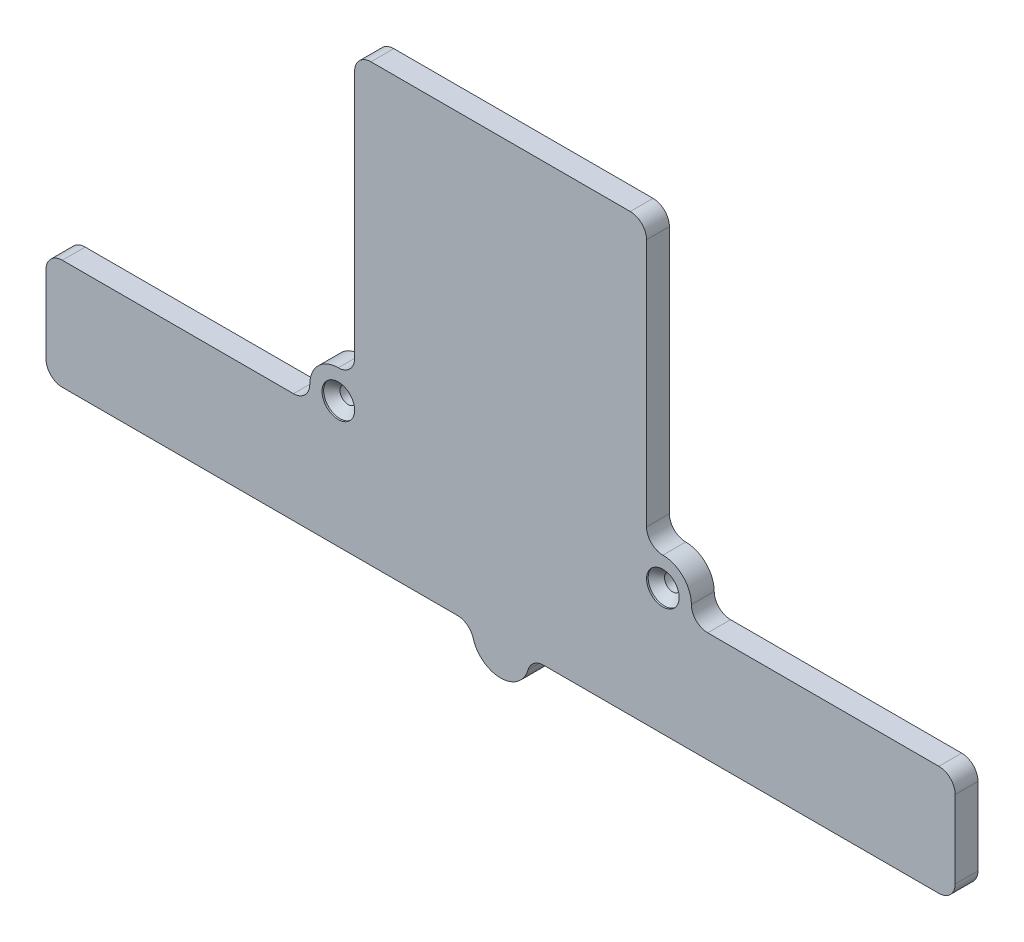
from build123d import *

# Parameters (mm, degrees)
BOSS_EXTRUDE1_DEPTH                            = 2.8
CUT_EXTRUDE1_REACH                             = 4.8
SKETCH3_R                                      = 1
CSK_FOR_M2_FLAT_HEAD_MACHINE_SCREW1_AT_2_COUNT = 2
CSK_FOR_M2_FLAT_HEAD_MACHINE_SCREW1_AT_2_PITCH = 39.8


with BuildPart() as part:
    # Sketch1 → Boss-Extrude1 (new body)
    with BuildSketch(Plane.XY):
        with BuildLine():
            Line((-53.75, -26.75), (-5.291502622, -26.75))
            ThreePointArc((-5.291502622, -26.75), (-4.085457244, -27.15455193), (-3.36731985, -28.204545455))
            ThreePointArc((-3.36731985, -28.204545455), (0, -30.75), (3.36731985, -28.204545455))
            ThreePointArc((3.36731985, -28.204545455), (4.085457244, -27.15455193), (5.291502622, -26.75))
            Line((5.291502622, -26.75), (53.75, -26.75))
            ThreePointArc((53.75, -26.75), (55.164213562, -26.164213562), (55.75, -24.75))
            Line((55.75, -24.75), (55.75, -15.25))
            ThreePointArc((55.75, -15.25), (55.164213562, -13.835786438), (53.75, -13.25))
            Line((53.75, -13.25), (25.4, -13.25))
            ThreePointArc((25.4, -13.25), (23.985786438, -12.664213562), (23.4, -11.25))
            ThreePointArc((23.4, -11.25), (22.374873734, -8.775126266), (19.9, -7.75))
            ThreePointArc((19.9, -7.75), (18.485786438, -7.164213562), (17.9, -5.75))
            Line((17.9, -5.75), (17.9, 24.75))
            ThreePointArc((17.9, 24.75), (17.314213562, 26.164213562), (15.9, 26.75))
            Line((15.9, 26.75), (-15.9, 26.75))
            ThreePointArc((-15.9, 26.75), (-17.314213562, 26.164213562), (-17.9, 24.75))
            Line((-17.9, 24.75), (-17.9, -5.75))
            ThreePointArc((-17.9, -5.75), (-18.485786438, -7.164213562), (-19.9, -7.75))
            ThreePointArc((-19.9, -7.75), (-22.374873734, -8.775126266), (-23.4, -11.25))
            ThreePointArc((-23.4, -11.25), (-23.985786438, -12.664213562), (-25.4, -13.25))
            Line((-25.4, -13.25), (-53.75, -13.25))
            ThreePointArc((-53.75, -13.25), (-55.164213562, -13.835786438), (-55.75, -15.25))
            Line((-55.75, -15.25), (-55.75, -24.75))
            ThreePointArc((-55.75, -24.75), (-55.164213562, -26.164213562), (-53.75, -26.75))
        make_face()
    extrude(amount=BOSS_EXTRUDE1_DEPTH)

    # Sketch3 → Cut-Extrude1 (cut, up to next)
    with BuildSketch(Plane.XY.offset(2.8), mode=Mode.PRIVATE) as cut_extrude1_sk1:
        with Locations((-19.9, -11.25)):
            Circle(SKETCH3_R)
    cut_extrude1_tool1 = extrude(cut_extrude1_sk1.sketch, amount=-CUT_EXTRUDE1_REACH, mode=Mode.PRIVATE) & part.part
    add(cut_extrude1_tool1.solids().sort_by_distance((-19.9, -11.25, 2.8))[0], mode=Mode.SUBTRACT)
    # Sketch3 → Cut-Extrude1 (cut, up to next)
    with BuildSketch(Plane.XY.offset(2.8), mode=Mode.PRIVATE) as cut_extrude1_sk2:
        with Locations((19.9, -11.25)):
            Circle(SKETCH3_R)
    cut_extrude1_tool2 = extrude(cut_extrude1_sk2.sketch, amount=-CUT_EXTRUDE1_REACH, mode=Mode.PRIVATE) & part.part
    add(cut_extrude1_tool2.solids().sort_by_distance((19.9, -11.25, 2.8))[0], mode=Mode.SUBTRACT)

    # Sketch4 → CSK for M2 Flat Head Machine Screw1 (revolve, cut)
    with BuildSketch(Plane(origin=(-19.9, -11.25, 2.8), x_dir=(0, -1, 0), z_dir=(1, 0, 0))):
        Polygon((0, 0), (0, 2.8), (1, 2.8), (1, 1.2), (2, 0.2), (2, 0), align=None)
    csk_for_m2_flat_head_machine_screw1 = revolve(axis=Axis((-19.9, -11.25, 9.15), (0, 0, -1)), mode=Mode.SUBTRACT)

    # CSK for M2 Flat Head Machine Screw1 at 2: CSK for M2 Flat Head Machine Screw1 ×2
    with Locations(*[(i * CSK_FOR_M2_FLAT_HEAD_MACHINE_SCREW1_AT_2_PITCH, 0, 0) for i in range(1, CSK_FOR_M2_FLAT_HEAD_MACHINE_SCREW1_AT_2_COUNT)]):
        add(csk_for_m2_flat_head_machine_screw1, mode=Mode.SUBTRACT)


solid = part.part
